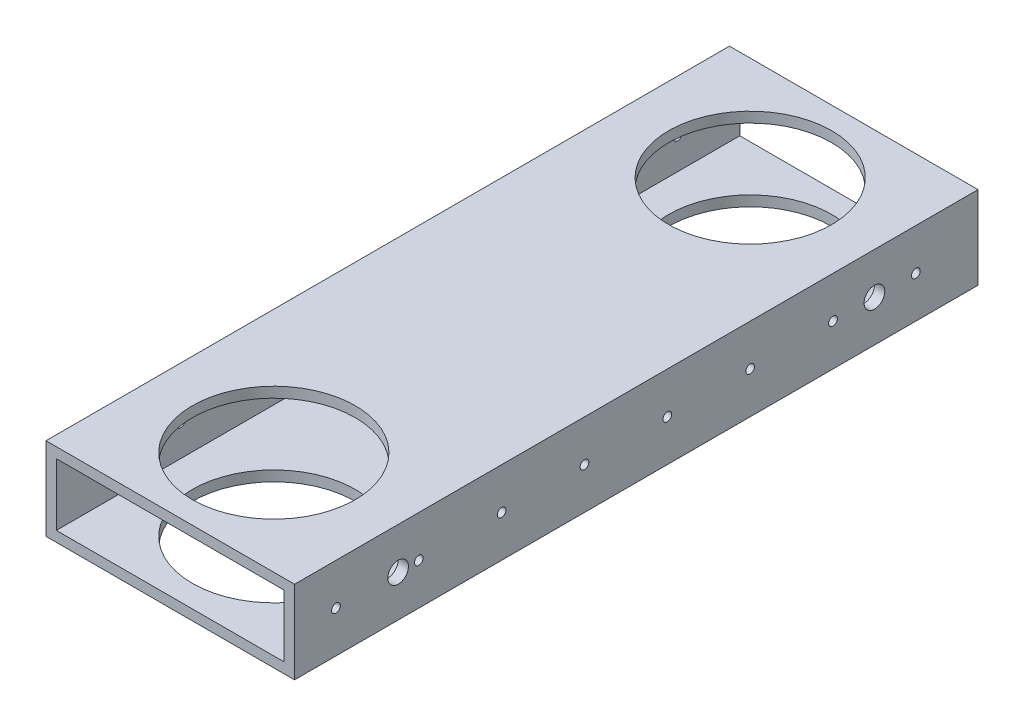
from build123d import *

# Parameters (mm, degrees)
SKETCH2_W           = 76.2
SKETCH2_H           = 25.4
SKETCH2_W_2         = 69.85
SKETCH2_H_2         = 19.05
EXTRUDE_THIN1_DEPTH = 209.55
SKETCH3_R           = 24.97201
CUT_EXTRUDE1_DEPTH  = 26.4
SKETCH4_R           = 1.3335
CUT_EXTRUDE2_DEPTH  = 77.2
LPATTERN1_COUNT     = 9
LPATTERN1_PITCH     = 25.4
SKETCH5_R           = 3.175
CUT_EXTRUDE3_DEPTH  = 77.2


with BuildPart() as part:
    # Sketch2 → Extrude-Thin1 (new body)
    with BuildSketch(Plane.XY):
        Rectangle(SKETCH2_W, SKETCH2_H)
        Rectangle(SKETCH2_W_2, SKETCH2_H_2, mode=Mode.SUBTRACT)
    extrude(amount=EXTRUDE_THIN1_DEPTH)

    # Sketch3 → Cut-Extrude1 (cut, through all)
    with BuildSketch(Plane(origin=(0, 12.7, 0), x_dir=(1, 0, 0), z_dir=(0, 1, 0))):
        with Locations((0, -177.8)):
            Circle(SKETCH3_R)
        with Locations((0, -31.75)):
            Circle(SKETCH3_R)
    extrude(amount=-CUT_EXTRUDE1_DEPTH, mode=Mode.SUBTRACT)

    # Sketch4 → Cut-Extrude2 (cut, through all)
    with BuildSketch(Plane(origin=(38.1, 0, 0), x_dir=(0, 0, -1), z_dir=(1, 0, 0))):
        with Locations((-196.85, 0)):
            Circle(SKETCH4_R)
    cut_extrude2 = extrude(amount=-CUT_EXTRUDE2_DEPTH, mode=Mode.SUBTRACT)

    # LPattern1: Cut-Extrude2 ×9
    with Locations(*[(0, 0, -i * LPATTERN1_PITCH) for i in range(1, LPATTERN1_COUNT)]):
        add(cut_extrude2, mode=Mode.SUBTRACT)

    # Sketch5 → Cut-Extrude3 (cut, through all)
    with BuildSketch(Plane(origin=(38.1, 0, 0), x_dir=(0, 0, -1), z_dir=(1, 0, 0))):
        with Locations((-31.75, 0)):
            Circle(SKETCH5_R)
        with Locations((-177.8, 0)):
            Circle(SKETCH5_R)
    extrude(amount=-CUT_EXTRUDE3_DEPTH, mode=Mode.SUBTRACT)


solid = part.part
